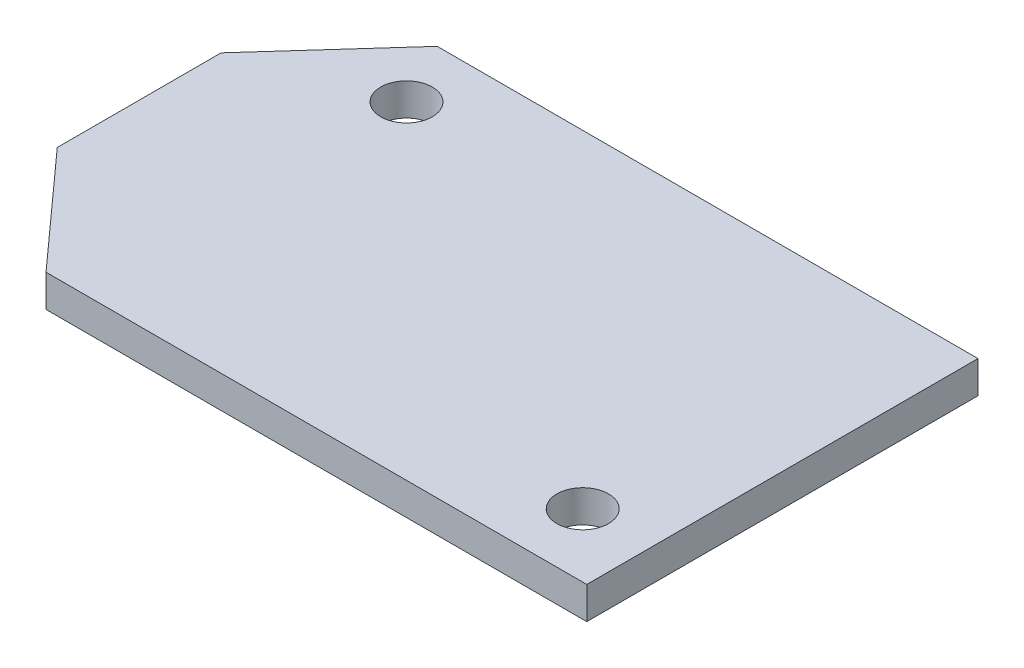
from build123d import *

# Parameters (mm, degrees)
SKETCH1_R           = 1.6
BOSS_EXTRUDE1_DEPTH = 2


with BuildPart() as part:
    # Sketch1 → Boss-Extrude1 (new body)
    with BuildSketch(Plane(origin=(0, 0, 0), x_dir=(1, 0, 0), z_dir=(0, 1, 0))):
        Polygon((-16.764, -12.1285), (16.764, -12.1285), (16.764, 12.1285), (-16.764, 12.1285), (-23.114, 5.08), (-23.114, -5.08), align=None)
        with Locations((12.574, -8.1915)):
            Circle(SKETCH1_R, mode=Mode.SUBTRACT)
        with Locations((-14.732, 8.1915)):
            Circle(SKETCH1_R, mode=Mode.SUBTRACT)
    extrude(amount=BOSS_EXTRUDE1_DEPTH)


solid = part.part
